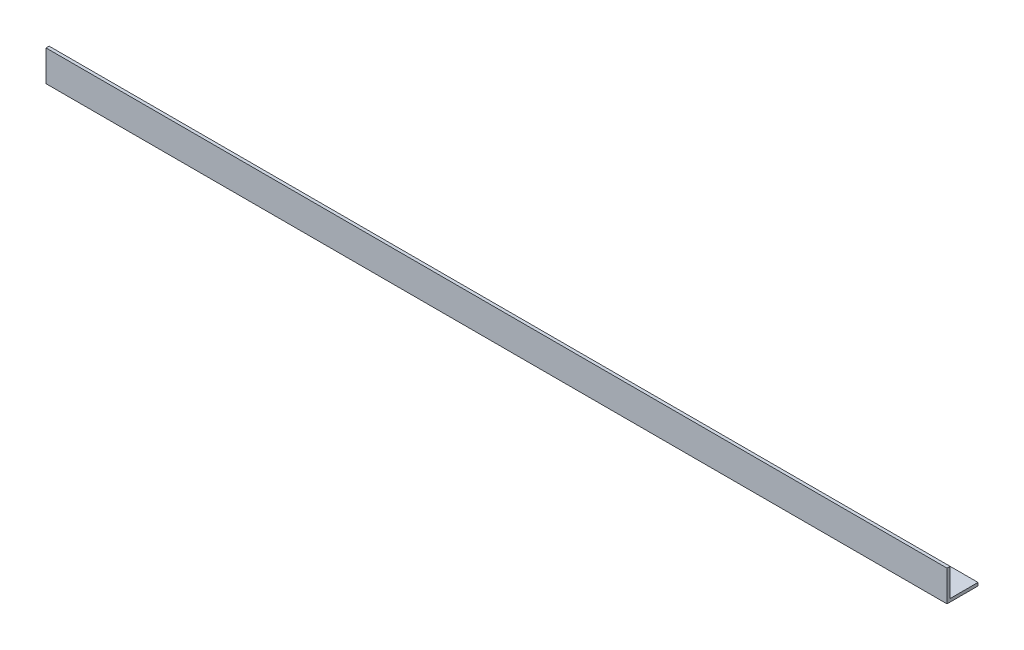
from build123d import *

# Parameters (mm, degrees)
EXTRUDE_1_DEPTH = 436


with BuildPart() as part:
    # Эскиз1 → Бобышка-Вытянуть1 (new body)
    with BuildSketch(Plane(origin=(0, 0, 0), x_dir=(0, 0, -1), z_dir=(1, 0, 0))):
        Polygon((0, 0), (0, 15), (1.5, 15), (1.5, 1.5), (15, 1.5), (15, 0), align=None)
    extrude(amount=EXTRUDE_1_DEPTH)


solid = part.part
